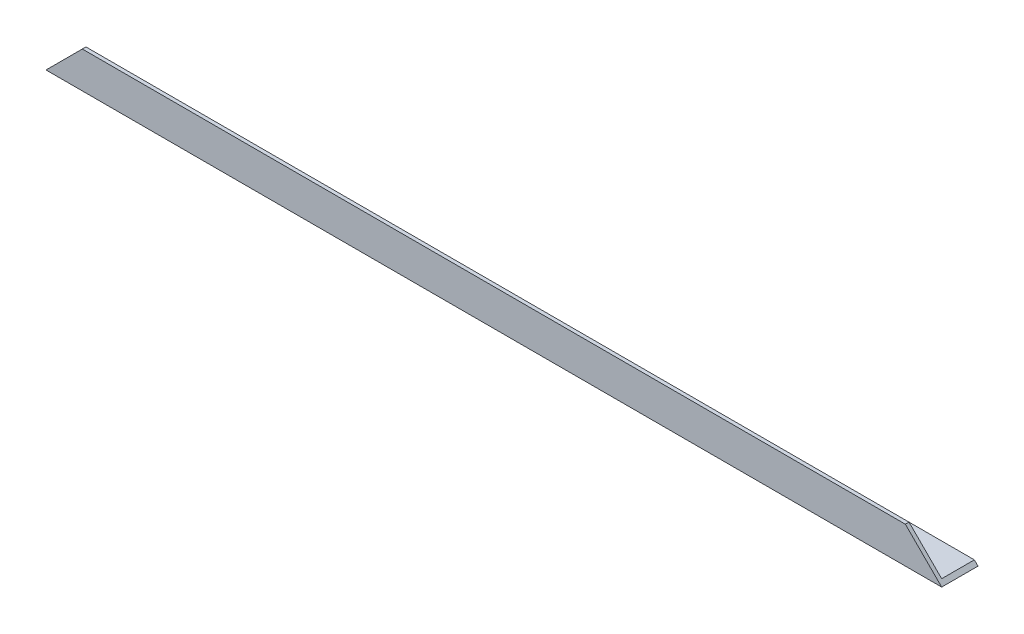
from build123d import *

# Parameters (mm, degrees)
EXTRUDE_1_DEPTH     = 370
CUT_EXTRUDE_1_DEPTH = 16


with BuildPart() as part:
    # Эскиз1 → Бобышка-Вытянуть1 (new body)
    with BuildSketch(Plane(origin=(0, 0, 0), x_dir=(0, 0, -1), z_dir=(1, 0, 0))):
        Polygon((0, 0), (0, 15), (1.5, 15), (1.5, 1.5), (15, 1.5), (15, 0), align=None)
    extrude(amount=EXTRUDE_1_DEPTH)

    # Эскиз2 → Вырез-Вытянуть1 (cut, through all)
    with BuildSketch(Plane.XY):
        Polygon((0, 0), (22.757405311, 22.757405311), (0, 22.757405311), align=None)
    cut_extrude_1 = extrude(amount=-CUT_EXTRUDE_1_DEPTH, mode=Mode.SUBTRACT)

    # Зеркальное отражение1: Вырез-Вытянуть1 across plane
    add(cut_extrude_1.mirror(Plane.ZY.offset(-185)), mode=Mode.SUBTRACT)


solid = part.part
